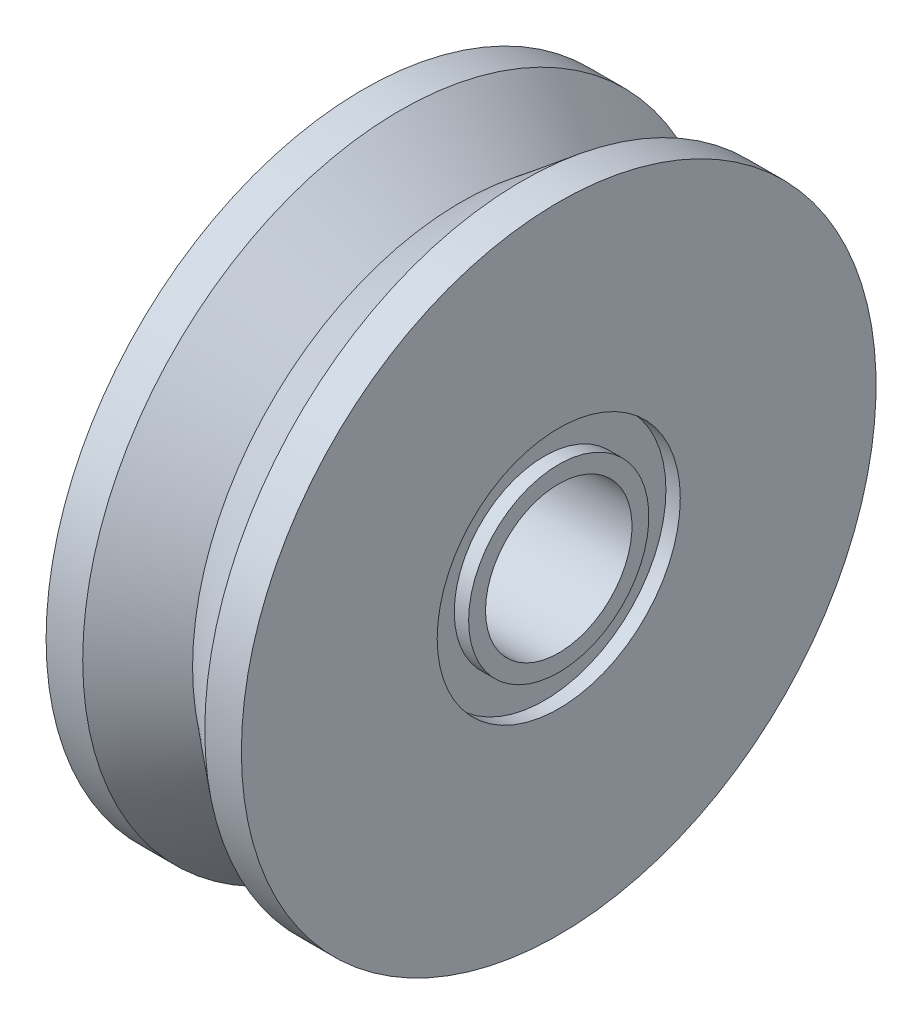
from build123d import *


with BuildPart() as part:
    # Sketch1 → Revolve1 (revolve)
    with BuildSketch(Plane.XY):
        Polygon((0, 6.5), (0.75, 6.5), (2, 5.5), (3.25, 6.5), (4, 6.5), (4, 2.48951049), (3.706293706, 2.48951049), (3.706293706, 1.846153846), (4, 1.846153846), (4, 1.5), (0, 1.5), (0, 1.846153846), (0.293706294, 1.846153846), (0.293706294, 2.48951049), (0, 2.48951049), align=None)
    revolve(axis=Axis((0, 0, 0), (1, 0, 0)))


solid = part.part
